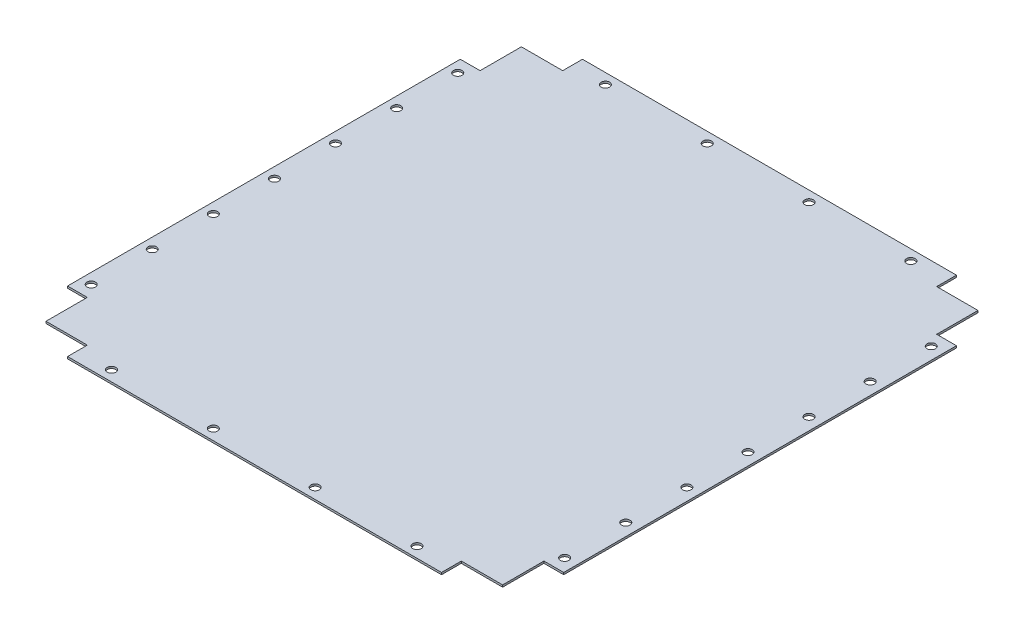
from build123d import *

# Parameters (mm, degrees)
SKETCH1_W           = 618.81
SKETCH1_H           = 642.21
BOSS_EXTRUDE1_DEPTH = 2.5
CUT_EXTRUDE1_DEPTH  = 2.5
SKETCH3_R           = 5.334
CUT_EXTRUDE2_DEPTH  = 10
SKETCH4_R           = 5.334
CUT_EXTRUDE3_DEPTH  = 10


with BuildPart() as part:
    # Sketch1 → Boss-Extrude1 (new body)
    with BuildSketch(Plane(origin=(0, 0, 0), x_dir=(1, 0, 0), z_dir=(0, 1, 0))):
        Rectangle(SKETCH1_W, SKETCH1_H)
    extrude(amount=BOSS_EXTRUDE1_DEPTH)

    # Sketch2 → Cut-Extrude1 (cut)
    with BuildSketch(Plane(origin=(0, 2.5, 0), x_dir=(1, 0, 0), z_dir=(0, 1, 0))):
        Polygon((-309.405, 321.105), (-233.205, 321.105), (-233.205, 296.445), (-284.745, 296.445), (-284.745, 244.905), (-309.405, 244.905), align=None)
        Polygon((-284.745, -244.905), (-309.405, -244.905), (-309.405, -321.105), (-233.205, -321.105), (-233.205, -296.445), (-284.745, -296.445), align=None)
        Polygon((284.745, -296.445), (284.745, -244.905), (309.405, -244.905), (309.405, -321.105), (233.205, -321.105), (233.205, -296.445), align=None)
        Polygon((284.745, 244.905), (309.405, 244.905), (309.405, 321.105), (233.205, 321.105), (233.205, 296.445), (284.745, 296.445), align=None)
    extrude(amount=-CUT_EXTRUDE1_DEPTH, mode=Mode.SUBTRACT)

    # Sketch3 → Cut-Extrude2 (cut)
    with BuildSketch(Plane(origin=(0, 0, 0), x_dir=(-1, 0, 0), z_dir=(0, -1, 0))):
        with Locations((-294.2768, -228.6018)):
            Circle(SKETCH3_R)
        with Locations((-294.2768, -152.4018)):
            Circle(SKETCH3_R)
        with Locations((-294.2768, -76.2018)):
            Circle(SKETCH3_R)
        with Locations((-294.2768, -0.0018)):
            Circle(SKETCH3_R)
        with Locations((-294.2768, 76.1982)):
            Circle(SKETCH3_R)
        with Locations((-294.2768, 152.3982)):
            Circle(SKETCH3_R)
        with Locations((-294.2768, 228.5982)):
            Circle(SKETCH3_R)
        with Locations((296.2732, -228.6018)):
            Circle(SKETCH3_R)
        with Locations((296.2732, -152.4018)):
            Circle(SKETCH3_R)
        with Locations((296.2732, -76.2018)):
            Circle(SKETCH3_R)
        with Locations((296.2732, -0.0018)):
            Circle(SKETCH3_R)
        with Locations((296.2732, 76.1982)):
            Circle(SKETCH3_R)
        with Locations((296.2732, 152.3982)):
            Circle(SKETCH3_R)
        with Locations((296.2732, 228.5982)):
            Circle(SKETCH3_R)
    extrude(amount=-CUT_EXTRUDE2_DEPTH, mode=Mode.SUBTRACT)

    # Sketch4 → Cut-Extrude3 (cut)
    with BuildSketch(Plane.XZ):
        with Locations((189.5018, 307.9768)):
            Circle(SKETCH4_R)
        with Locations((62.5018, 307.9768)):
            Circle(SKETCH4_R)
        with Locations((-64.4982, 307.9768)):
            Circle(SKETCH4_R)
        with Locations((-191.4982, 307.9768)):
            Circle(SKETCH4_R)
        with Locations((-191.4982, -307.9768)):
            Circle(SKETCH4_R)
        with Locations((-64.4982, -307.9768)):
            Circle(SKETCH4_R)
        with Locations((62.5018, -307.9768)):
            Circle(SKETCH4_R)
        with Locations((189.5018, -307.9768)):
            Circle(SKETCH4_R)
    extrude(amount=-CUT_EXTRUDE3_DEPTH, mode=Mode.SUBTRACT)


solid = part.part
